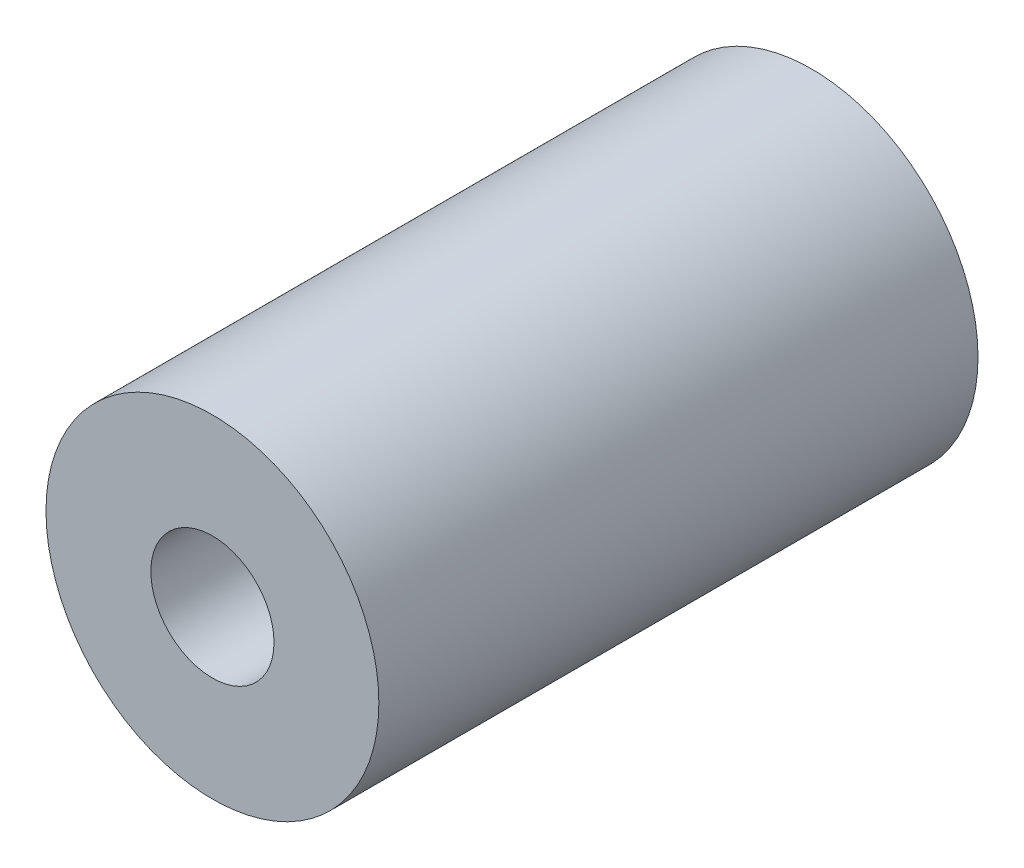
from build123d import *

# Parameters (mm, degrees)
SKETCH1_R           = 5
SKETCH1_R_2         = 1.85
BOSS_EXTRUDE1_DEPTH = 18


with BuildPart() as part:
    # Sketch1 → Boss-Extrude1 (new body)
    with BuildSketch(Plane.XY):
        Circle(SKETCH1_R)
        Circle(SKETCH1_R_2, mode=Mode.SUBTRACT)
    extrude(amount=BOSS_EXTRUDE1_DEPTH)


solid = part.part
